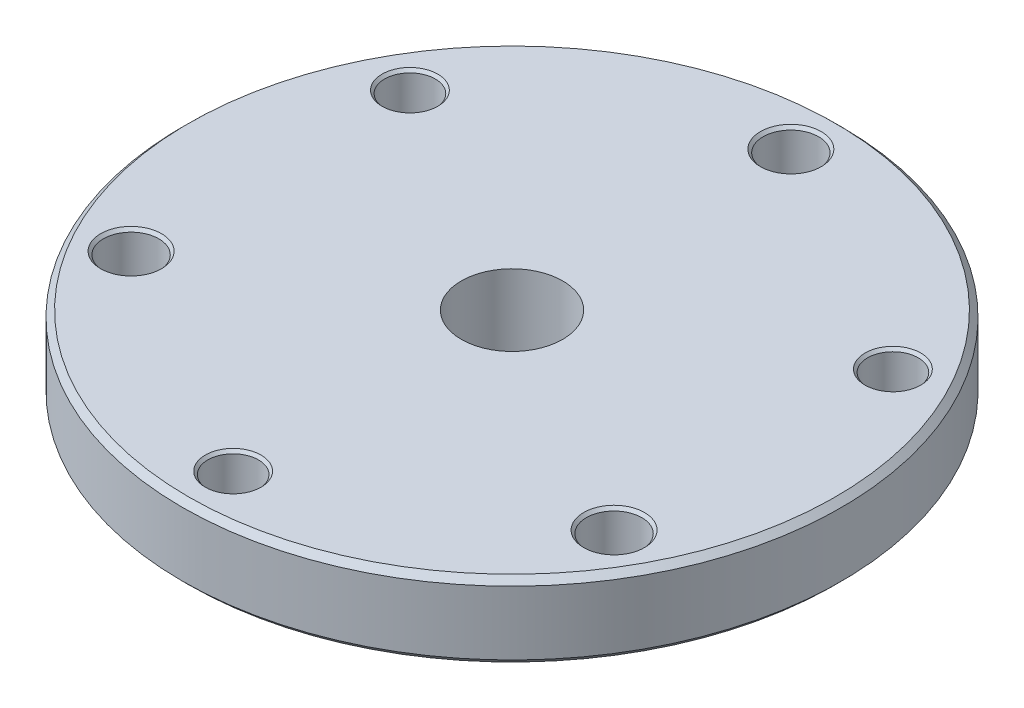
from build123d import *

# Parameters (mm, degrees)
SKETCH1_R                        = 82.55
EXTRUDE1_DEPTH                   = 19.05
F_1_1_DIAMETER_HOLE2_D           = 25.4
F_1_1_DIAMETER_HOLE2_DEPTH       = 19.05
F_1_2_20_TAPPED_HOLE1_AT_2_COUNT = 2
F_1_2_20_TAPPED_HOLE1_AT_2_PITCH = 120.983748909
F_1_2_20_TAPPED_HOLE1_AT_3_COUNT = 2
F_1_2_20_TAPPED_HOLE1_AT_3_PITCH = 120.983748909
F_1_2_CLEARANCE_HOLE1_AT_2_COUNT = 2
F_1_2_CLEARANCE_HOLE1_AT_2_PITCH = 120.983748909
F_1_2_CLEARANCE_HOLE1_AT_3_COUNT = 2
F_1_2_CLEARANCE_HOLE1_AT_3_PITCH = 120.983748909
CHAMFER6_SIZE                    = 1.524


with BuildPart() as part:
    # Sketch1 → Extrude1 (new body)
    with BuildSketch(Plane(origin=(0, 0, 0), x_dir=(1, 0, 0), z_dir=(0, 1, 0))):
        with Locations(Location((0, 0, 0), (0, 0, 270))):  # turned: the seam where the file's is
            Circle(SKETCH1_R)
    extrude(amount=EXTRUDE1_DEPTH)

    # 1 _1_ Diameter Hole2
    with Locations(Plane(origin=(0, 19.05, 0), x_dir=(-1, 0, 0), z_dir=(0, 1, 0))):
        with Locations((0, 0)):
            Hole(F_1_1_DIAMETER_HOLE2_D / 2, depth=F_1_1_DIAMETER_HOLE2_DEPTH)

    # Sketch12 → 1_2-20 Tapped Hole1 (revolve, cut)
    with BuildSketch(Plane(origin=(0, 19.05, 69.85), x_dir=(0, 0, 1), z_dir=(1, 0, 0))):
        Polygon((0, 0), (0, 19.05), (6.985, 19.05), (6.35, 18.319516061), (6.35, 0.730483939), (6.985, 0), align=None)
    f_1_2_20_tapped_hole1 = revolve(axis=Axis((0, 25.4, 69.85), (0, -1, 0)), mode=Mode.SUBTRACT)

    # 1_2-20 Tapped Hole1 at 2: 1_2-20 Tapped Hole1 ×2
    with Locations(*[Vector(-0.5, 0, -0.866025404) * (i * F_1_2_20_TAPPED_HOLE1_AT_2_PITCH) for i in range(1, F_1_2_20_TAPPED_HOLE1_AT_2_COUNT)]):
        add(f_1_2_20_tapped_hole1, mode=Mode.SUBTRACT)

    # 1_2-20 Tapped Hole1 at 3: 1_2-20 Tapped Hole1 ×2
    with Locations(*[Vector(0.5, 0, -0.866025404) * (i * F_1_2_20_TAPPED_HOLE1_AT_3_PITCH) for i in range(1, F_1_2_20_TAPPED_HOLE1_AT_3_COUNT)]):
        add(f_1_2_20_tapped_hole1, mode=Mode.SUBTRACT)

    # Sketch14 → 1_2 Clearance Hole1 (revolve, cut)
    with BuildSketch(Plane(origin=(0, 19.05, -69.85), x_dir=(0, 0, 1), z_dir=(1, 0, 0))):
        Polygon((0, 0), (0, 19.05), (7.62, 19.05), (6.94563, 18.274226057), (6.94563, 0.775773943), (7.62, 0), align=None)
    f_1_2_clearance_hole1 = revolve(axis=Axis((0, 25.4, -69.85), (0, -1, 0)), mode=Mode.SUBTRACT)

    # 1_2 Clearance Hole1 at 2: 1_2 Clearance Hole1 ×2
    with Locations(*[Vector(-0.5, 0, 0.866025404) * (i * F_1_2_CLEARANCE_HOLE1_AT_2_PITCH) for i in range(1, F_1_2_CLEARANCE_HOLE1_AT_2_COUNT)]):
        add(f_1_2_clearance_hole1, mode=Mode.SUBTRACT)

    # 1_2 Clearance Hole1 at 3: 1_2 Clearance Hole1 ×2
    with Locations(*[Vector(0.5, 0, 0.866025404) * (i * F_1_2_CLEARANCE_HOLE1_AT_3_PITCH) for i in range(1, F_1_2_CLEARANCE_HOLE1_AT_3_COUNT)]):
        add(f_1_2_clearance_hole1, mode=Mode.SUBTRACT)

    # Chamfer6
    chamfer6_edges = [part.edges().sort_by_distance(p)[0] for p in [
        (0, 0, -82.55),
        (0, 19.05, -82.55),
    ]]
    chamfer(chamfer6_edges, length=CHAMFER6_SIZE)


solid = part.part
